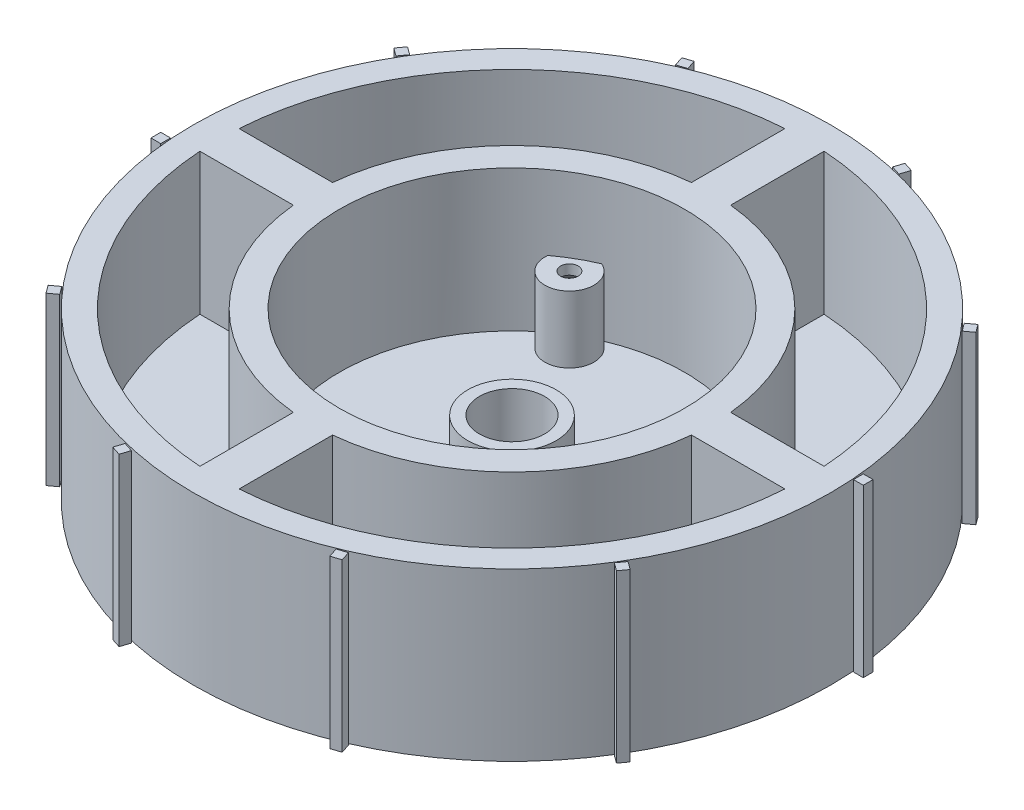
from build123d import *

# Parameters (mm, degrees)
SKETCH1_R                                    = 32.5
BOSS_EXTRUDE1_DEPTH                          = 17
SHELL1_T                                     = -2.6
SKETCH4_R                                    = 4.5
BOSS_EXTRUDE3_DEPTH                          = 5
SKETCH5_R                                    = 3.325
CUT_EXTRUDE2_DEPTH                           = 47.913324333
SKETCH22_R                                   = 20.4
SKETCH22_R_2                                 = 17.6
BOSS_EXTRUDE10_DEPTH                         = 14.4
SKETCH24_R                                   = 2.5
BOSS_EXTRUDE11_DEPTH                         = 6.8
CSK_SLOT_FOR_M1_6_COUNTERSUNK_FLAT_H_2_COUNT = 2
CSK_SLOT_FOR_M1_6_COUNTERSUNK_FLAT_H_2_PITCH = 27.712812921
CSK_SLOT_FOR_M1_6_COUNTERSUNK_FLAT_H_3_COUNT = 2
CSK_SLOT_FOR_M1_6_COUNTERSUNK_FLAT_H_3_PITCH = 27.712812921
SKETCH29_W                                   = 1
SKETCH29_H                                   = 17
BOSS_EXTRUDE13_DEPTH                         = 1
CIRPATTERN6_COUNT                            = 10
BOSS_EXTRUDE14_DEPTH                         = 14.4


with BuildPart() as part:
    # Sketch1 → Boss-Extrude1 (new body)
    with BuildSketch(Plane(origin=(0, 0, 0), x_dir=(1, 0, 0), z_dir=(0, 1, 0))):
        with Locations(Location((0, 0, 0), (0, 0, 270))):
            Circle(SKETCH1_R)
    extrude(amount=BOSS_EXTRUDE1_DEPTH)

    # Shell1
    shell1_openings = [part.faces().sort_by_distance(p)[0] for p in [
        (0, 17, 0),
    ]]
    offset(amount=SHELL1_T, openings=shell1_openings, kind=Kind.INTERSECTION)

    # Sketch4 → Boss-Extrude3 (add)
    with BuildSketch(Plane(origin=(0, 2.6, 0), x_dir=(1, 0, 0), z_dir=(0, 1, 0))):
        with Locations(Location((0, 0, 0), (0, 0, 270))):
            Circle(SKETCH4_R)
    extrude(amount=BOSS_EXTRUDE3_DEPTH)

    # Sketch5 → Cut-Extrude2 (cut, through all)
    with BuildSketch(Plane(origin=(0, 7.6, 0), x_dir=(1, 0, 0), z_dir=(0, 1, 0))):
        with Locations(Location((0, 0, 0), (0, 0, 270))):
            Circle(SKETCH5_R)
    extrude(amount=-CUT_EXTRUDE2_DEPTH, mode=Mode.SUBTRACT)

    # Sketch22 → Boss-Extrude10 (add)
    with BuildSketch(Plane(origin=(0, 2.6, 0), x_dir=(1, 0, 0), z_dir=(0, 1, 0))):
        with Locations(Location((0, 0, 0), (0, 0, 270))):
            Circle(SKETCH22_R)
        with Locations(Location((0, 0, 0), (0, 0, 270))):
            Circle(SKETCH22_R_2, mode=Mode.SUBTRACT)
    extrude(amount=BOSS_EXTRUDE10_DEPTH)

    # Sketch24 → Boss-Extrude11 (add)
    with BuildSketch(Plane(origin=(0, 2.6, 0), x_dir=(1, 0, 0), z_dir=(0, 1, 0))):
        with Locations((-8, 13.856406461)):
            Circle(SKETCH24_R)
        with Locations((16, 0)):
            Circle(SKETCH24_R)
        with Locations((-8, -13.856406461)):
            Circle(SKETCH24_R)
    extrude(amount=BOSS_EXTRUDE11_DEPTH)

    # Sketch26 → CSK SLOT for M1.6 Countersunk Flat Head (revolve, cut)
    with BuildSketch(Plane(origin=(-8, 0, 13.856406461), x_dir=(0, 0, -1), z_dir=(1, 0, 0))):
        Polygon((0, 0), (0, 17), (0.9, 17), (0.9, 8.4), (1.8, 7.5), (1.8, 0), align=None)
    csk_slot_for_m1_6_countersunk_flat_head = revolve(axis=Axis((-8, -6.35, 13.856406461), (0, 1, 0)), mode=Mode.SUBTRACT)

    # CSK SLOT for M1.6 Countersunk Flat H 2: CSK SLOT for M1.6 Countersunk Flat Head ×2
    with Locations(*[(0, 0, -i * CSK_SLOT_FOR_M1_6_COUNTERSUNK_FLAT_H_2_PITCH) for i in range(1, CSK_SLOT_FOR_M1_6_COUNTERSUNK_FLAT_H_2_COUNT)]):
        add(csk_slot_for_m1_6_countersunk_flat_head, mode=Mode.SUBTRACT)

    # CSK SLOT for M1.6 Countersunk Flat H 3: CSK SLOT for M1.6 Countersunk Flat Head ×2
    with Locations(*[Vector(0.8660254037844364, 0, -0.5000000000000041) * (i * CSK_SLOT_FOR_M1_6_COUNTERSUNK_FLAT_H_3_PITCH) for i in range(1, CSK_SLOT_FOR_M1_6_COUNTERSUNK_FLAT_H_3_COUNT)]):
        add(csk_slot_for_m1_6_countersunk_flat_head, mode=Mode.SUBTRACT)

    # Sketch30 → Boss-Extrude14 (add)
    with BuildSketch(Plane(origin=(0, 2.6, 0), x_dir=(1, 0, 0), z_dir=(0, 1, 0))):
        with BuildLine():
            Line((-2, -20.301724065), (-2, -29.83303538))
            ThreePointArc((-2, -29.83303538), (0, -29.9), (2, -29.83303538))
            Line((2, -29.83303538), (2, -20.301724065))
            ThreePointArc((2, -20.301724065), (0, -20.4), (-2, -20.301724065))
        make_face()
        with BuildLine():
            Line((-20.301724065, -2), (-29.83303538, -2))
            ThreePointArc((-29.83303538, -2), (-29.9, 0), (-29.83303538, 2))
            Line((-29.83303538, 2), (-20.301724065, 2))
            ThreePointArc((-20.301724065, 2), (-20.4, 0), (-20.301724065, -2))
        make_face()
        with BuildLine():
            Line((-2, 20.301724065), (-2, 29.83303538))
            ThreePointArc((-2, 29.83303538), (0, 29.9), (2, 29.83303538))
            Line((2, 29.83303538), (2, 20.301724065))
            ThreePointArc((2, 20.301724065), (0, 20.4), (-2, 20.301724065))
        make_face()
        with BuildLine():
            Line((20.301724065, 2), (29.83303538, 2))
            ThreePointArc((29.83303538, 2), (29.9, 0), (29.83303538, -2))
            Line((29.83303538, -2), (20.301724065, -2))
            ThreePointArc((20.301724065, -2), (20.4, 0), (20.301724065, 2))
        make_face()
    extrude(amount=BOSS_EXTRUDE14_DEPTH)


with BuildPart() as body_2:
    # Sketch29 → Boss-Extrude13 (new body)
    with BuildSketch(Plane.ZY.offset(32.5)):
        with Locations((2.825, 8.5)):
            Rectangle(SKETCH29_W, SKETCH29_H)
    extrude(amount=BOSS_EXTRUDE13_DEPTH)


with BuildPart() as cirpattern6_1:
    # CirPattern6: pattern copy
    add(body_2.part.rotate(Axis((0, 0, 0), (0, 1, 0)), 1 * 360 / CIRPATTERN6_COUNT))


with BuildPart() as cirpattern6_2:
    # CirPattern6: pattern copy
    add(body_2.part.rotate(Axis((0, 0, 0), (0, 1, 0)), 2 * 360 / CIRPATTERN6_COUNT))


with BuildPart() as cirpattern6_3:
    # CirPattern6: pattern copy
    add(body_2.part.rotate(Axis((0, 0, 0), (0, 1, 0)), 3 * 360 / CIRPATTERN6_COUNT))


with BuildPart() as cirpattern6_4:
    # CirPattern6: pattern copy
    add(body_2.part.rotate(Axis((0, 0, 0), (0, 1, 0)), 4 * 360 / CIRPATTERN6_COUNT))


with BuildPart() as cirpattern6_5:
    # CirPattern6: pattern copy
    add(body_2.part.rotate(Axis((0, 0, 0), (0, 1, 0)), 5 * 360 / CIRPATTERN6_COUNT))


with BuildPart() as cirpattern6_6:
    # CirPattern6: pattern copy
    add(body_2.part.rotate(Axis((0, 0, 0), (0, 1, 0)), 6 * 360 / CIRPATTERN6_COUNT))


with BuildPart() as cirpattern6_7:
    # CirPattern6: pattern copy
    add(body_2.part.rotate(Axis((0, 0, 0), (0, 1, 0)), 7 * 360 / CIRPATTERN6_COUNT))


with BuildPart() as cirpattern6_8:
    # CirPattern6: pattern copy
    add(body_2.part.rotate(Axis((0, 0, 0), (0, 1, 0)), 8 * 360 / CIRPATTERN6_COUNT))


with BuildPart() as cirpattern6_9:
    # CirPattern6: pattern copy
    add(body_2.part.rotate(Axis((0, 0, 0), (0, 1, 0)), 9 * 360 / CIRPATTERN6_COUNT))


solid = Compound([part.part, body_2.part, cirpattern6_1.part, cirpattern6_2.part, cirpattern6_3.part, cirpattern6_4.part, cirpattern6_5.part, cirpattern6_6.part, cirpattern6_7.part, cirpattern6_8.part, cirpattern6_9.part])
